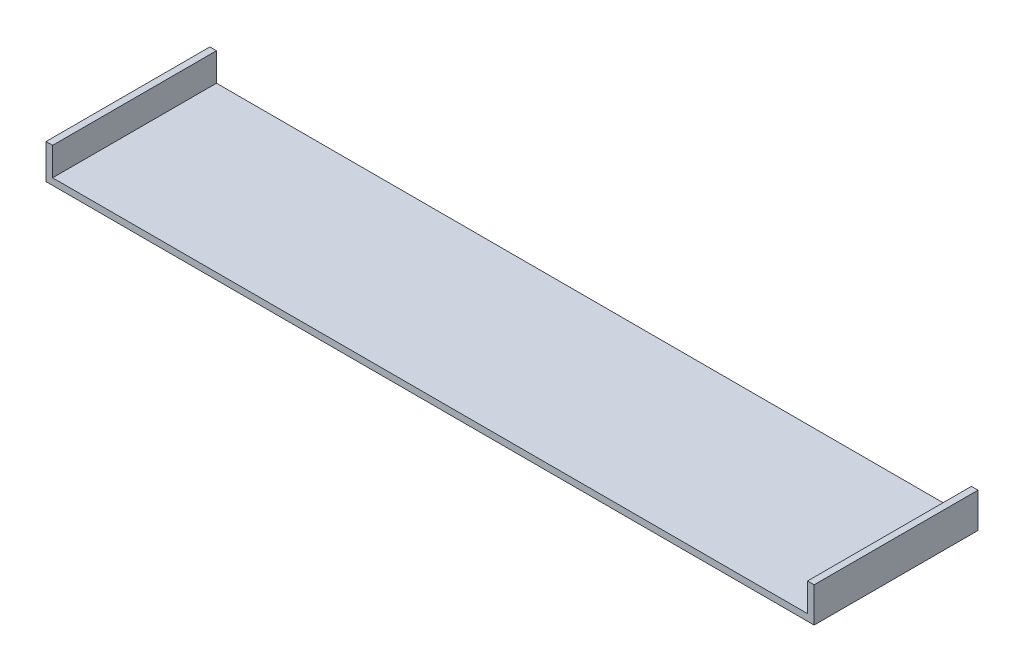
from build123d import *

# Parameters (mm, degrees)
EXTRUDE_THIN1_DEPTH = 150


with BuildPart() as part:
    # Sketch1 → Extrude-Thin1 (new body)
    with BuildSketch(Plane.XY):
        Polygon((-250.514148937, 25.753634758), (-250.514148937, 0), (440.503291061, 0), (440.503291061, 25.915671281), (446.551474959, 25.915671281), (446.551474959, -6.048183898), (-256.562332835, -6.048183898), (-256.562332835, 25.753634758), align=None)
    extrude(amount=EXTRUDE_THIN1_DEPTH)


solid = part.part
